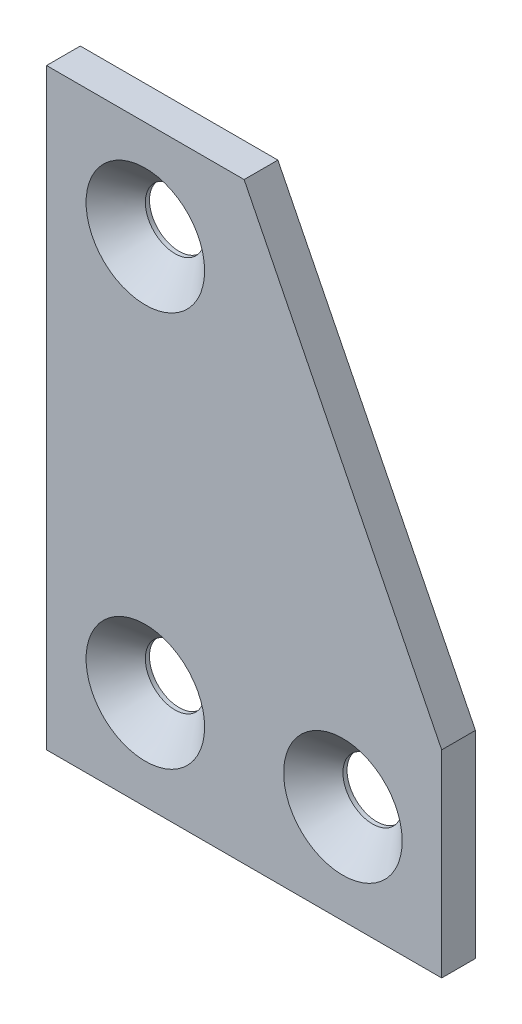
from build123d import *

# Parameters (mm, degrees)
BOSS_EXTRUDE1_DEPTH = 1.708
SKETCH2_R           = 3
CUT_EXTRUDE1_DEPTH  = 4.416
CHAMFER1_SIZE       = 3


with BuildPart() as part:
    # Sketch1 → Boss-Extrude1 (new body, symmetric)
    with BuildSketch(Plane.XY):
        Polygon((-20, -30), (-20, 30), (0, 30), (20, -10), (20, -30), align=None)
    extrude(amount=BOSS_EXTRUDE1_DEPTH, both=True)

    # Sketch2 → Cut-Extrude1 (cut, through all)
    with BuildSketch(Plane.XY.offset(1.708)):
        with Locations((-10, 20)):
            Circle(SKETCH2_R)
        with Locations((-10, -20)):
            Circle(SKETCH2_R)
        with Locations((10, -20)):
            Circle(SKETCH2_R)
    extrude(amount=-CUT_EXTRUDE1_DEPTH, mode=Mode.SUBTRACT)

    # Chamfer1
    chamfer1_edges = [part.edges().sort_by_distance(p)[0] for p in [
        (-13, 20, 1.708),
        (-13, -20, 1.708),
        (7, -20, 1.708),
    ]]
    chamfer(chamfer1_edges, length=CHAMFER1_SIZE)


solid = part.part
